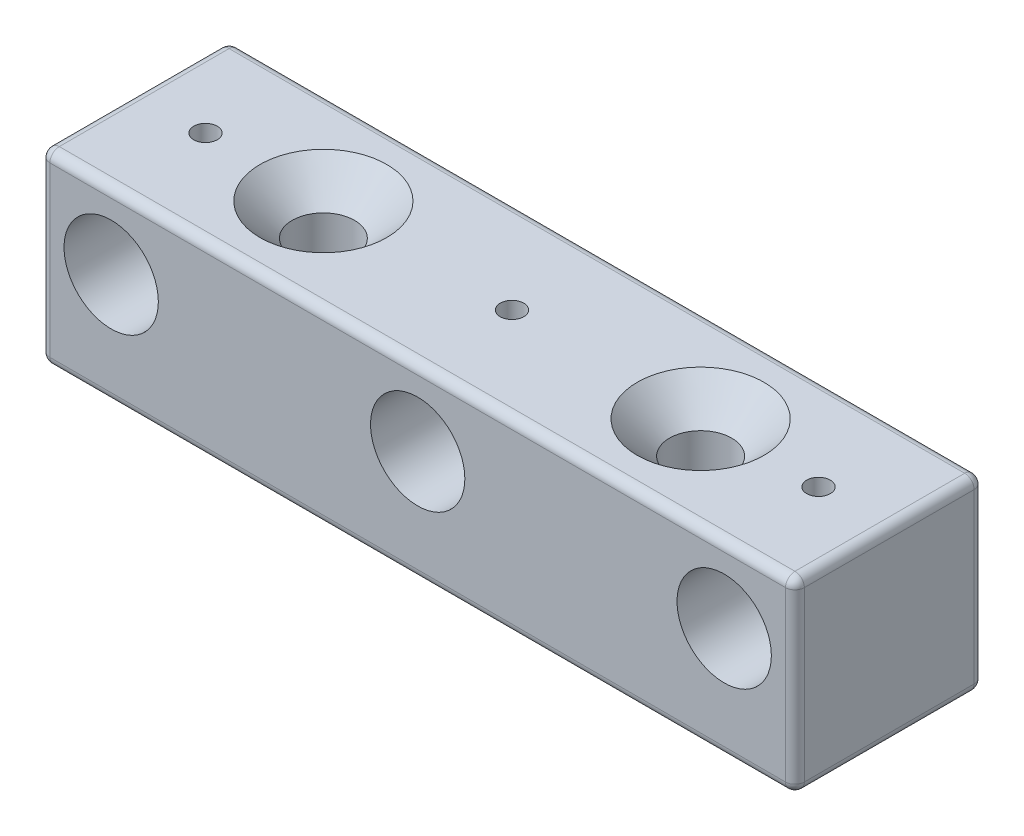
from build123d import *

# Parameters (mm, degrees)
SKETCH1_W                     = 80
SKETCH1_H                     = 20
BOSS_EXTRUDE1_DEPTH           = 19.85
CUT_EXTRUDE1_REACH            = 86.818
SKETCH2_R                     = 3.1
CUT_EXTRUDE2_REACH            = 86.818
SKETCH3_R                     = 5
FILLET1_R                     = 1
CSK_FOR_M6_SFHCS1_D           = 6.6
CSK_FOR_M6_SFHCS1_DEPTH       = 19.85
CSK_FOR_M6_SFHCS1_CSINK_D     = 13.44
CSK_FOR_M6_SFHCS1_CSINK_ANGLE = 90
M3X0_5_TAPPED_HOLE1_REACH     = 86.818
M3X0_5_TAPPED_HOLE1_BORE_R    = 1.25


with BuildPart() as part:
    # Sketch1 → Boss-Extrude1 (new body)
    with BuildSketch(Plane(origin=(0, 0, 0), x_dir=(1, 0, 0), z_dir=(0, 1, 0))):
        with Locations((40, 10)):
            Rectangle(SKETCH1_W, SKETCH1_H)
    extrude(amount=BOSS_EXTRUDE1_DEPTH)

    # Sketch2 → Cut-Extrude1 (cut, up to next)
    with BuildSketch(Plane(origin=(0, 19.85, 0), x_dir=(1, 0, 0), z_dir=(0, 1, 0)), mode=Mode.PRIVATE) as cut_extrude1_sk1:
        with Locations(Location((20, 10, 0), (0, 0, 270))):
            Circle(SKETCH2_R)
    cut_extrude1_tool1 = extrude(cut_extrude1_sk1.sketch, amount=-CUT_EXTRUDE1_REACH, mode=Mode.PRIVATE) & part.part
    # Sketch2 → Cut-Extrude1 (cut, up to next)
    with BuildSketch(Plane(origin=(0, 19.85, 0), x_dir=(1, 0, 0), z_dir=(0, 1, 0)), mode=Mode.PRIVATE) as cut_extrude1_sk2:
        with Locations(Location((60, 10, 0), (0, 0, 270))):
            Circle(SKETCH2_R)
    cut_extrude1_tool2 = extrude(cut_extrude1_sk2.sketch, amount=-CUT_EXTRUDE1_REACH, mode=Mode.PRIVATE) & part.part
    add(cut_extrude1_tool1.solids().sort_by_distance((20, 19.85, -10))[0], mode=Mode.SUBTRACT)
    add(cut_extrude1_tool2.solids().sort_by_distance((60, 19.85, -10))[0], mode=Mode.SUBTRACT)

    # Sketch3 → Cut-Extrude2 (cut, up to next)
    with BuildSketch(Plane.XY, mode=Mode.PRIVATE) as cut_extrude2_sk1:
        with Locations((7.5, 11.85)):
            Circle(SKETCH3_R)
    cut_extrude2_tool1 = extrude(cut_extrude2_sk1.sketch, amount=-CUT_EXTRUDE2_REACH, mode=Mode.PRIVATE) & part.part
    # Sketch3 → Cut-Extrude2 (cut, up to next)
    with BuildSketch(Plane.XY, mode=Mode.PRIVATE) as cut_extrude2_sk2:
        with Locations((72.5, 11.85)):
            Circle(SKETCH3_R)
    cut_extrude2_tool2 = extrude(cut_extrude2_sk2.sketch, amount=-CUT_EXTRUDE2_REACH, mode=Mode.PRIVATE) & part.part
    # Sketch3 → Cut-Extrude2 (cut, up to next)
    with BuildSketch(Plane.XY, mode=Mode.PRIVATE) as cut_extrude2_sk3:
        with Locations((40, 11.85)):
            Circle(SKETCH3_R)
    cut_extrude2_tool3 = extrude(cut_extrude2_sk3.sketch, amount=-CUT_EXTRUDE2_REACH, mode=Mode.PRIVATE) & part.part
    add(cut_extrude2_tool1.solids().sort_by_distance((7.5, 11.85, 0))[0], mode=Mode.SUBTRACT)
    add(cut_extrude2_tool2.solids().sort_by_distance((72.5, 11.85, 0))[0], mode=Mode.SUBTRACT)
    add(cut_extrude2_tool3.solids().sort_by_distance((40, 11.85, 0))[0], mode=Mode.SUBTRACT)

    # Fillet1
    fillet1_edges = [part.edges().sort_by_distance(p)[0] for p in [
        (80, 19.85, -10),
        (40, 19.85, -20),
        (0, 19.85, -10),
        (40, 0, -20),
        (80, 0, -10),
        (40, 0, 0),
        (0, 0, -10),
        (40, 19.85, 0),
        (0, 9.925, -20),
        (80, 9.925, -20),
        (80, 9.925, 0),
        (0, 9.925, 0),
    ]]
    fillet(fillet1_edges, radius=FILLET1_R)

    # CSK for M6 SFHCS1
    with Locations(Plane(origin=(0, 19.85, 0), x_dir=(1, 0, 0), z_dir=(0, 1, 0))):
        with Locations((60, 10), (20, 10)):
            CounterSinkHole(CSK_FOR_M6_SFHCS1_D / 2, CSK_FOR_M6_SFHCS1_CSINK_D / 2, depth=CSK_FOR_M6_SFHCS1_DEPTH, counter_sink_angle=CSK_FOR_M6_SFHCS1_CSINK_ANGLE)

    # M3x0.5 Tapped Hole1 bore → M3x0.5 Tapped Hole1 (cut, up to next)
    with BuildSketch(Plane(origin=(0, 19.85, 0), x_dir=(1, 0, 0), z_dir=(0, 1, 0)), mode=Mode.PRIVATE) as m3x0_5_tapped_hole1_sk1:
        with Locations((7.5, 10)):
            Circle(M3X0_5_TAPPED_HOLE1_BORE_R)
    m3x0_5_tapped_hole1_tool1 = extrude(m3x0_5_tapped_hole1_sk1.sketch, amount=-M3X0_5_TAPPED_HOLE1_REACH, mode=Mode.PRIVATE) & part.part
    # M3x0.5 Tapped Hole1 bore → M3x0.5 Tapped Hole1 (cut, up to next)
    with BuildSketch(Plane(origin=(0, 19.85, 0), x_dir=(1, 0, 0), z_dir=(0, 1, 0)), mode=Mode.PRIVATE) as m3x0_5_tapped_hole1_sk2:
        with Locations((40, 10)):
            Circle(M3X0_5_TAPPED_HOLE1_BORE_R)
    m3x0_5_tapped_hole1_tool2 = extrude(m3x0_5_tapped_hole1_sk2.sketch, amount=-M3X0_5_TAPPED_HOLE1_REACH, mode=Mode.PRIVATE) & part.part
    # M3x0.5 Tapped Hole1 bore → M3x0.5 Tapped Hole1 (cut, up to next)
    with BuildSketch(Plane(origin=(0, 19.85, 0), x_dir=(1, 0, 0), z_dir=(0, 1, 0)), mode=Mode.PRIVATE) as m3x0_5_tapped_hole1_sk3:
        with Locations((72.5, 10)):
            Circle(M3X0_5_TAPPED_HOLE1_BORE_R)
    m3x0_5_tapped_hole1_tool3 = extrude(m3x0_5_tapped_hole1_sk3.sketch, amount=-M3X0_5_TAPPED_HOLE1_REACH, mode=Mode.PRIVATE) & part.part
    add(m3x0_5_tapped_hole1_tool1.solids().sort_by_distance((7.5, 19.85, -10))[0], mode=Mode.SUBTRACT)
    add(m3x0_5_tapped_hole1_tool2.solids().sort_by_distance((40, 19.85, -10))[0], mode=Mode.SUBTRACT)
    add(m3x0_5_tapped_hole1_tool3.solids().sort_by_distance((72.5, 19.85, -10))[0], mode=Mode.SUBTRACT)


solid = part.part
